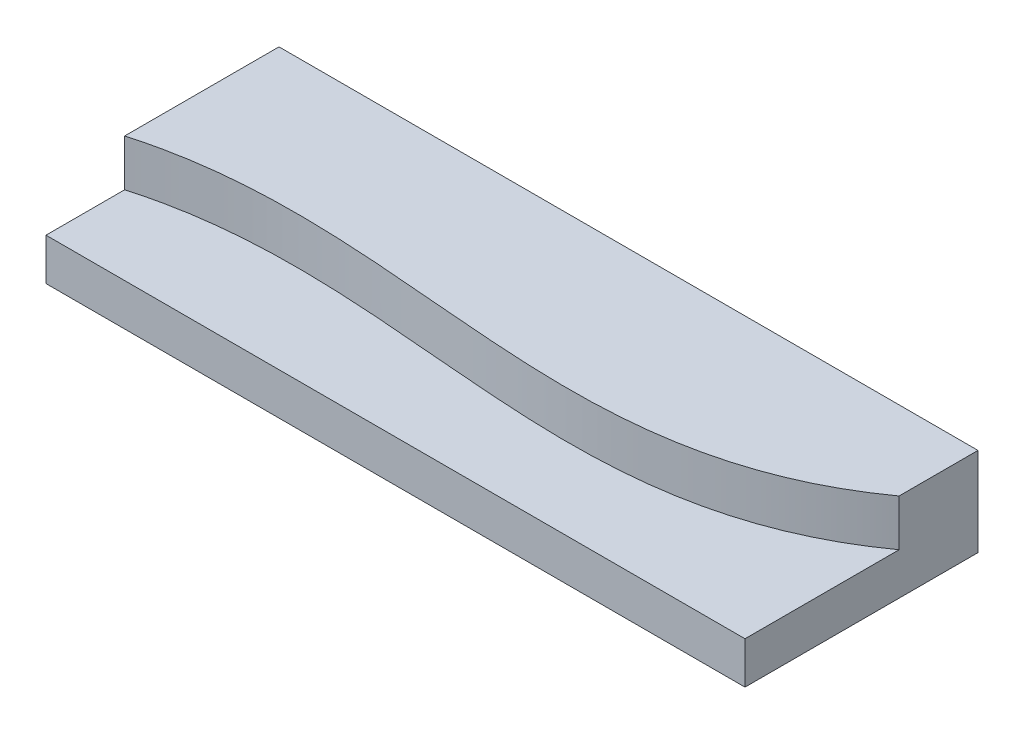
from build123d import *

# Parameters (mm, degrees)
SKETCH1_W           = 150
SKETCH1_H           = 50
BOSS_EXTRUDE1_DEPTH = 19
CUT_EXTRUDE1_DEPTH  = 10


with BuildPart() as part:
    # Sketch1 → Boss-Extrude1 (new body)
    with BuildSketch(Plane(origin=(0, 0, 0), x_dir=(1, 0, 0), z_dir=(0, 1, 0))):
        with Locations((75, 25)):
            Rectangle(SKETCH1_W, SKETCH1_H)
    extrude(amount=BOSS_EXTRUDE1_DEPTH)

    # Sketch2 → Cut-Extrude1 (cut)
    with BuildSketch(Plane(origin=(0, 19, 0), x_dir=(1, 0, 0), z_dir=(0, 1, 0))):
        with BuildLine():
            Line((-14.15766915, 11.43597738), (-14.15766915, -14.105632465))
            Line((-14.15766915, -14.105632465), (161.61937252, -14.105632465))
            Line((161.61937252, -14.105632465), (161.61937252, 43.164685263))
            add(Edge.make_bspline(
                [(-14.15766915, 11.43597738), (43.406827576, 39.699894181), (110.750368018, -9.289380037), (161.61937252, 43.164685263)],
                knots=[0, 0, 0, 0, 1, 1, 1, 1], degree=3))
        make_face()
    extrude(amount=-CUT_EXTRUDE1_DEPTH, mode=Mode.SUBTRACT)


solid = part.part
